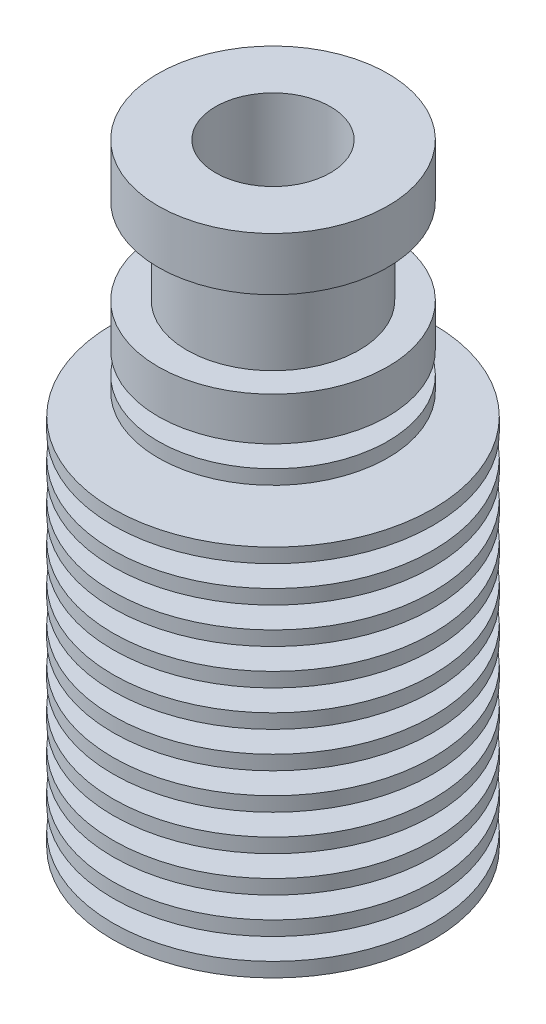
from build123d import *


with BuildPart() as part:
    # Sketch1 → Revolve1 (revolve)
    with BuildSketch(Plane.XY):
        Polygon((4, 21.35), (8, 21.35), (8, 17.65), (6, 17.65), (6, 11.65), (8, 11.65), (8, 8.65), (4.4, 8.65), (4.4, 7.15), (8, 7.15), (8, 6.15), (4.4, 6.15), (4.4, 4.65), (11.15, 4.65), (11.15, 3.65), (4.6, 3.65), (4.6, 2.15), (11.15, 2.15), (11.15, 1.15), (4.8, 1.15), (4.8, -0.35), (11.15, -0.35), (11.15, -1.35), (4.95, -1.35), (4.95, -2.85), (11.15, -2.85), (11.15, -3.85), (5.15, -3.85), (5.15, -5.35), (11.15, -5.35), (11.15, -6.35), (5.35, -6.35), (5.35, -7.85), (11.15, -7.85), (11.15, -8.85), (5.5, -8.85), (5.5, -10.35), (11.15, -10.35), (11.15, -11.35), (5.7, -11.35), (5.7, -12.85), (11.15, -12.85), (11.15, -13.85), (5.9, -13.85), (5.9, -15.35), (11.15, -15.35), (11.15, -16.35), (6.05, -16.35), (6.05, -17.85), (11.15, -17.85), (11.15, -18.85), (6.25, -18.85), (6.25, -20.35), (11.15, -20.35), (11.15, -21.35), (3.5, -21.35), (3.5, -6.55), (2.1, -5.741709623), (2.1, 14.019605677), (4, 15.35), align=None)
    revolve(axis=Axis((0, 21.35, 0), (0, -1, 0)))


solid = part.part
